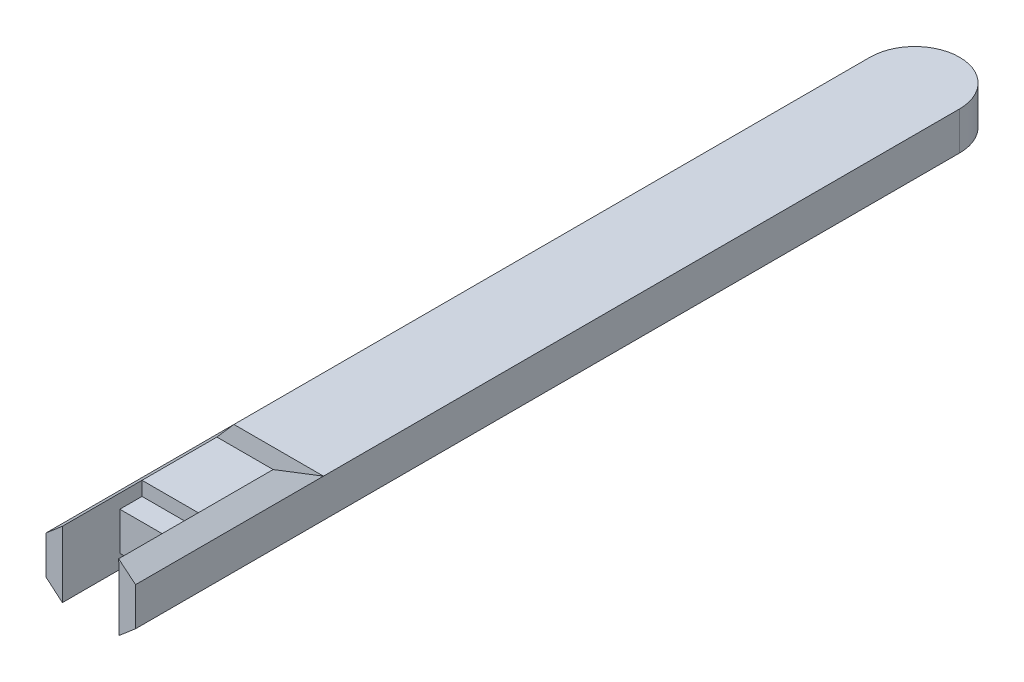
from build123d import *

# Parameters (mm, degrees)
SKETCH1_W           = 13.4
SKETCH1_H           = 123.3
BOSS_EXTRUDE1_DEPTH = 5.72
BOSS_EXTRUDE2_DEPTH = 13.4
BOSS_EXTRUDE3_DEPTH = 13.4
SKETCH5_W           = 8.5
SKETCH5_H           = 8.6
CUT_EXTRUDE1_DEPTH  = 13.4
BOSS_EXTRUDE4_DEPTH = 11.95
BOSS_EXTRUDE5_DEPTH = 11.95
CUT_EXTRUDE3_DEPTH  = 16.5
BOSS_EXTRUDE6_DEPTH = 11.95
CUT_EXTRUDE6_DEPTH  = 16.6
CUT_EXTRUDE7_DEPTH  = 16.6
BOSS_EXTRUDE7_DEPTH = 11.95
CUT_EXTRUDE8_DEPTH  = 16.6


with BuildPart() as part:
    # Sketch1 → Boss-Extrude1 (new body)
    with BuildSketch(Plane(origin=(0, 0, 0), x_dir=(1, 0, 0), z_dir=(0, 1, 0))):
        Rectangle(SKETCH1_W, SKETCH1_H)
        with BuildLine():
            ThreePointArc((-6.7, 61.65), (0, 68.35), (6.7, 61.65))
            Line((6.7, 61.65), (-6.7, 61.65))
        make_face()
    extrude(amount=BOSS_EXTRUDE1_DEPTH)

    # Sketch3 → Boss-Extrude2 (add)
    with BuildSketch(Plane(origin=(6.7, 0, 0), x_dir=(0, 0, -1), z_dir=(1, 0, 0))):
        Polygon((-49.73, 7.81), (-49.73, 5.72), (-33.53, 5.72), (-38.53, 7.81), align=None)
    extrude(amount=-BOSS_EXTRUDE2_DEPTH)

    # Sketch4 → Boss-Extrude3 (add)
    with BuildSketch(Plane(origin=(6.7, 0, 0), x_dir=(0, 0, -1), z_dir=(1, 0, 0))):
        Polygon((-49.73, 0), (-33.53, 0), (-38.53, -2.09), (-49.73, -2.09), align=None)
    extrude(amount=-BOSS_EXTRUDE3_DEPTH)

    # Sketch5 → Cut-Extrude1 (cut)
    with BuildSketch(Plane.XZ):
        with Locations((0, 57.35)):
            Rectangle(SKETCH5_W, SKETCH5_H)
    extrude(amount=-CUT_EXTRUDE1_DEPTH, mode=Mode.SUBTRACT)

    # Sketch6 → Boss-Extrude4 (add)
    with BuildSketch(Plane.XY.offset(61.65)):
        Polygon((-4.25, 5.72), (-6.7, 5.72), (-4.25, 7.81), align=None)
    extrude(amount=-BOSS_EXTRUDE4_DEPTH)

    # Sketch8 → Boss-Extrude5 (add)
    with BuildSketch(Plane.XY.offset(61.65)):
        Polygon((6.7, 5.72), (4.169608926, 7.81), (4.25, 5.72), align=None)
    extrude(amount=-BOSS_EXTRUDE5_DEPTH)

    # Sketch10 → Cut-Extrude3 (cut)
    with BuildSketch(Plane.XY.offset(49.73)):
        Polygon((-6.7, 7.81), (-6.7, 5.72), (-4.25, 7.81), align=None)
    extrude(amount=-CUT_EXTRUDE3_DEPTH, mode=Mode.SUBTRACT)

    # Sketch11 → Boss-Extrude6 (add)
    with BuildSketch(Plane.XY.offset(61.65)):
        Polygon((4.245506051, 0), (4.245506051, -2.09), (6.7, 0), align=None)
    extrude(amount=-BOSS_EXTRUDE6_DEPTH)

    # Sketch13 → Cut-Extrude6 (cut)
    with BuildSketch(Plane.XY.offset(49.73)):
        Polygon((6.7, 0), (4.245506051, -2.09), (6.7, -2.09), align=None)
    extrude(amount=-CUT_EXTRUDE6_DEPTH, mode=Mode.SUBTRACT)

    # Sketch14 → Cut-Extrude7 (cut)
    with BuildSketch(Plane.XY.offset(49.73)):
        Polygon((4.169608926, 7.81), (6.7, 7.81), (6.7, 5.72), align=None)
    extrude(amount=-CUT_EXTRUDE7_DEPTH, mode=Mode.SUBTRACT)

    # Sketch15 → Boss-Extrude7 (add)
    with BuildSketch(Plane.XY.offset(61.65)):
        Polygon((-4.25, -2.09), (-6.7, 0), (-4.25, 0), align=None)
    extrude(amount=-BOSS_EXTRUDE7_DEPTH)

    # Sketch16 → Cut-Extrude8 (cut)
    with BuildSketch(Plane.XY.offset(49.73)):
        Polygon((-6.7, 0), (-6.7, -2.09), (-4.25, -2.09), align=None)
    extrude(amount=-CUT_EXTRUDE8_DEPTH, mode=Mode.SUBTRACT)


solid = part.part
